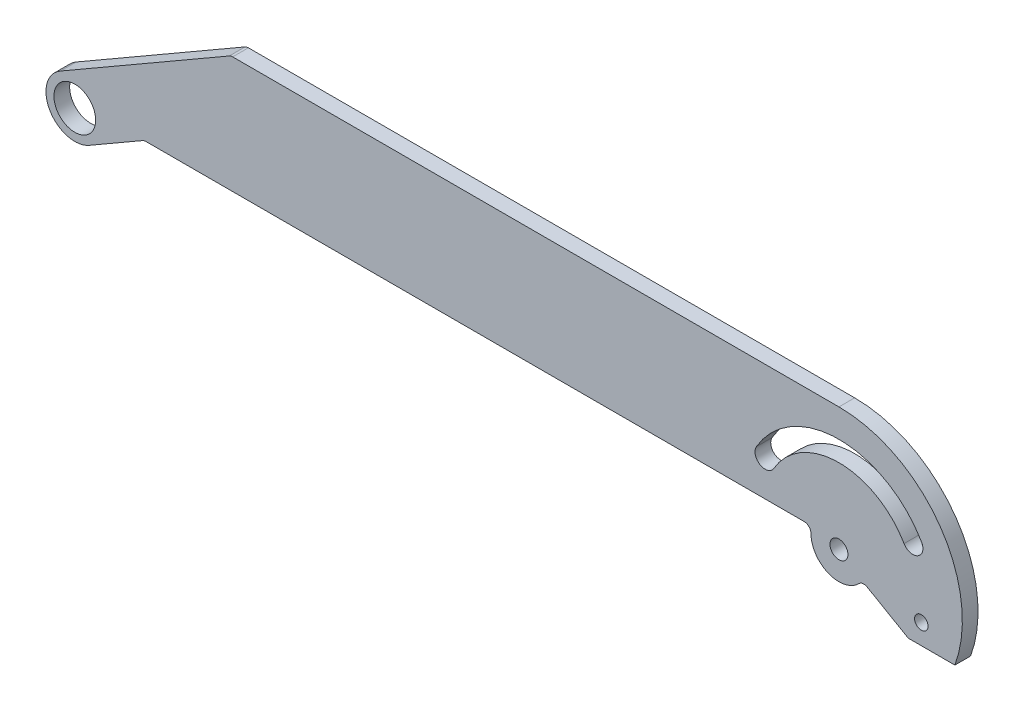
from build123d import *

# Parameters (mm, degrees)
SKETCH1_W           = 500
SKETCH1_H           = 150
SKETCH1_R           = 9.3
SKETCH1_R_2         = 3
SKETCH1_R_3         = 4
BOSS_EXTRUDE1_DEPTH = 7
CUT_EXTRUDE1_DEPTH  = 7
FILLET2_R           = 3


with BuildPart() as part:
    # Sketch1 → Boss-Extrude1 (new body)
    with BuildSketch(Plane.XY):
        with Locations((200, 0)):
            Rectangle(SKETCH1_W, SKETCH1_H)
        Circle(SKETCH1_R, mode=Mode.SUBTRACT)
        with BuildLine():
            ThreePointArc((303.793920425, 21.250000148), (340.59999997, 42.5), (377.406079545, 21.250000201))
            ThreePointArc((377.406079545, 21.250000201), (375.758965412, 15.102885723), (369.61185099, 16.750000063))
            ThreePointArc((369.61185099, 16.750000063), (340.600001147, 33.5), (311.588150157, 16.750002051))
            ThreePointArc((311.588150157, 16.750002051), (305.441035607, 15.102885134), (303.793920425, 21.250000148))
        make_face(mode=Mode.SUBTRACT)
        with Locations((377.305181399, -9.835123714)):
            Circle(SKETCH1_R_2, mode=Mode.SUBTRACT)
        with Locations((340.6, 0)):
            Circle(SKETCH1_R_3, mode=Mode.SUBTRACT)
    extrude(amount=BOSS_EXTRUDE1_DEPTH)

    # Sketch3 → Cut-Extrude1 (cut)
    with BuildSketch(Plane.XY.offset(7)):
        with BuildLine():
            Line((69.562794416, 55), (-50, 55))
            Line((-50, 55), (-50, -75))
            Line((-50, -75), (450, -75))
            Line((450, -75), (450, 55))
            Line((450, 55), (340.6, 55))
            ThreePointArc((340.6, 55), (379.490872965, 38.890872965), (395.6, 0))
            ThreePointArc((395.6, 0), (394.762205793, -9.563235), (392.274346776, -18.835123714))
            ThreePointArc((392.274346776, -18.835123714), (329.562623749, -53.881131442), (285.681879129, 3))
            Line((285.681879129, 3), (30.896152423, 3))
            Line((30.896152423, 3), (6.425, -11.128426439))
            ThreePointArc((6.425, -11.128426439), (-11.128426439, -6.425), (-6.425, 11.128426439))
            Line((-6.425, 11.128426439), (69.562794416, 55))
        make_face()
        with BuildLine():
            Line((328.4653389, 3), (285.681879129, 3))
            ThreePointArc((285.681879129, 3), (329.562623749, -53.881131442), (392.274346776, -18.835123714))
            Line((392.274346776, -18.835123714), (371.498146439, -18.835123714))
            Line((371.498146439, -18.835123714), (350.968741122, -6.981347115))
            ThreePointArc((350.968741122, -6.981347115), (335.531820751, -11.426441226), (328.4653389, 3))
        make_face()
        Polygon((-50, 75), (-50, 55), (69.562794416, 55), (340.6, 55), (450, 55), (450, 75), align=None)
    extrude(amount=-CUT_EXTRUDE1_DEPTH, mode=Mode.SUBTRACT)

    # Fillet2
    fillet2_edges = [part.edges().sort_by_distance(p)[0] for p in [
        (69.562794416, 55, 3.5),
        (30.896152423, 3, 3.5),
        (328.4653389, 3, 3.5),
        (350.968741122, -6.981347115, 3.5),
    ]]
    fillet(fillet2_edges, radius=FILLET2_R)


solid = part.part
